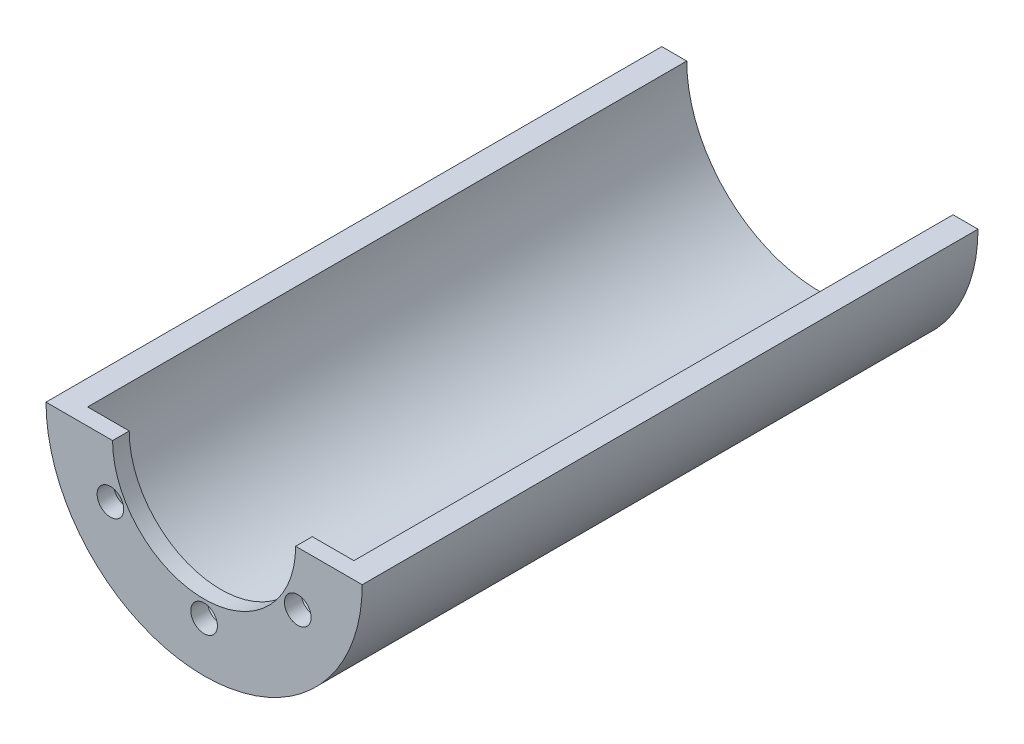
from build123d import *

# Parameters (mm, degrees)
SKETCH1_R           = 9.5
BOSS_EXTRUDE1_DEPTH = 36
SKETCH2_R           = 8
CUT_EXTRUDE1_DEPTH  = 37
SKETCH4_W           = 19
SKETCH4_H           = 9.5
CUT_EXTRUDE2_DEPTH  = 37
BOSS_EXTRUDE3_DEPTH = 1
SKETCH8_R           = 5.5
CUT_EXTRUDE9_DEPTH  = 38
SKETCH9_R           = 0.8
CUT_EXTRUDE10_DEPTH = 2
CIRPATTERN2_COUNT   = 6


with BuildPart() as part:
    # Sketch1 → Boss-Extrude1 (new body)
    with BuildSketch(Plane.XY):
        Circle(SKETCH1_R)
    extrude(amount=BOSS_EXTRUDE1_DEPTH)

    # Sketch2 → Cut-Extrude1 (cut, through all)
    with BuildSketch(Plane.XY.offset(36)):
        Circle(SKETCH2_R)
    extrude(amount=-CUT_EXTRUDE1_DEPTH, mode=Mode.SUBTRACT)

    # Sketch4 → Cut-Extrude2 (cut, through all)
    with BuildSketch(Plane.XY.offset(36)):
        with Locations((0, 4.75)):
            Rectangle(SKETCH4_W, SKETCH4_H)
    extrude(amount=-CUT_EXTRUDE2_DEPTH, mode=Mode.SUBTRACT)

    # Sketch5 → Boss-Extrude3 (add)
    with BuildSketch(Plane.XY.offset(36)):
        with BuildLine():
            ThreePointArc((8, 0), (0, -8), (-8, 0))
            Line((-8, 0), (-9.5, 0))
            ThreePointArc((-9.5, 0), (0, -9.5), (9.5, 0))
            Line((9.5, 0), (8, 0))
        make_face()
        with BuildLine():
            Line((8, 0), (-8, 0))
            ThreePointArc((-8, 0), (0, -8), (8, 0))
        make_face()
    extrude(amount=BOSS_EXTRUDE3_DEPTH)

    # Sketch8 → Cut-Extrude9 (cut, through all)
    with BuildSketch(Plane.XY.offset(37)):
        Circle(SKETCH8_R)
    extrude(amount=-CUT_EXTRUDE9_DEPTH, mode=Mode.SUBTRACT)

    # Sketch9 → Cut-Extrude10 (cut, through all)
    with BuildSketch(Plane(origin=(0, 0, 36), x_dir=(-1, 0, 0), z_dir=(0, 0, -1))):
        with Locations((0, -6.5)):
            Circle(SKETCH9_R)
    cut_extrude10 = extrude(amount=-CUT_EXTRUDE10_DEPTH, mode=Mode.SUBTRACT)

    # CirPattern2: Cut-Extrude10 ×6 about axis
    cirpattern2_axis = Axis((0, 0, 0), (0, 0, 1))
    for i in range(1, CIRPATTERN2_COUNT):
        add(cut_extrude10.rotate(cirpattern2_axis, i * 360 / CIRPATTERN2_COUNT), mode=Mode.SUBTRACT)


solid = part.part
